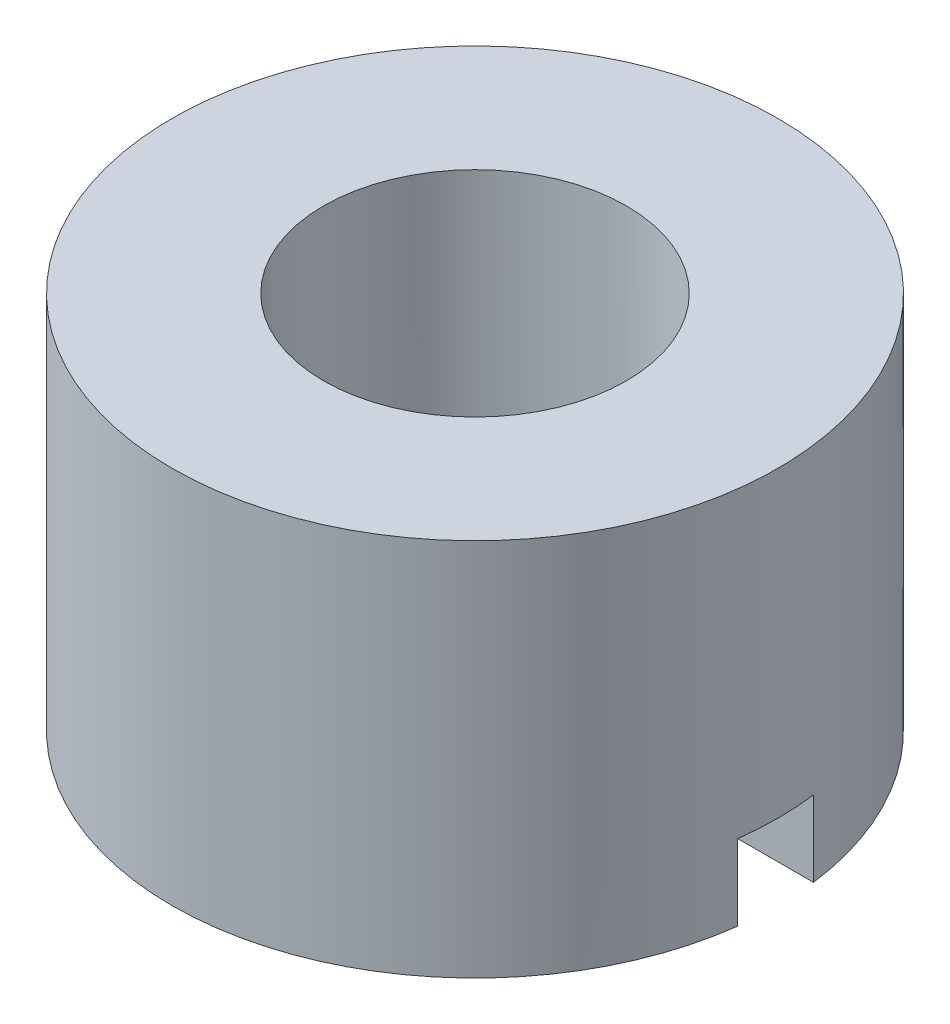
from build123d import *

# Parameters (mm, degrees)
SKETCH2_W               = 4
SKETCH2_H               = 10
SKETCH3_W               = 2
SKETCH3_H               = 2
CUT_EXTRUDE1_DEPTH      = 9
CUT_EXTRUDE1_DEPTH_BACK = 9


with BuildPart() as part:
    # Sketch2 → Revolve1 (revolve)
    with BuildSketch(Plane(origin=(0, 0, 0), x_dir=(0, 0, -1), z_dir=(1, 0, 0))):
        with Locations((6, -0.173076923)):
            Rectangle(SKETCH2_W, SKETCH2_H)
    revolve(axis=Axis((0, 8.057692308, 0), (0, -1, 0)))

    # Sketch3 → Cut-Extrude1 (cut, two sides)
    with BuildSketch(Plane(origin=(0, 0, 0), x_dir=(0, 0, -1), z_dir=(1, 0, 0))) as cut_extrude1_sk:
        with Locations((0, -4.173076923)):
            Rectangle(SKETCH3_W, SKETCH3_H)
    extrude(amount=CUT_EXTRUDE1_DEPTH, mode=Mode.SUBTRACT)
    extrude(cut_extrude1_sk.sketch, amount=-CUT_EXTRUDE1_DEPTH_BACK, mode=Mode.SUBTRACT)


solid = part.part
